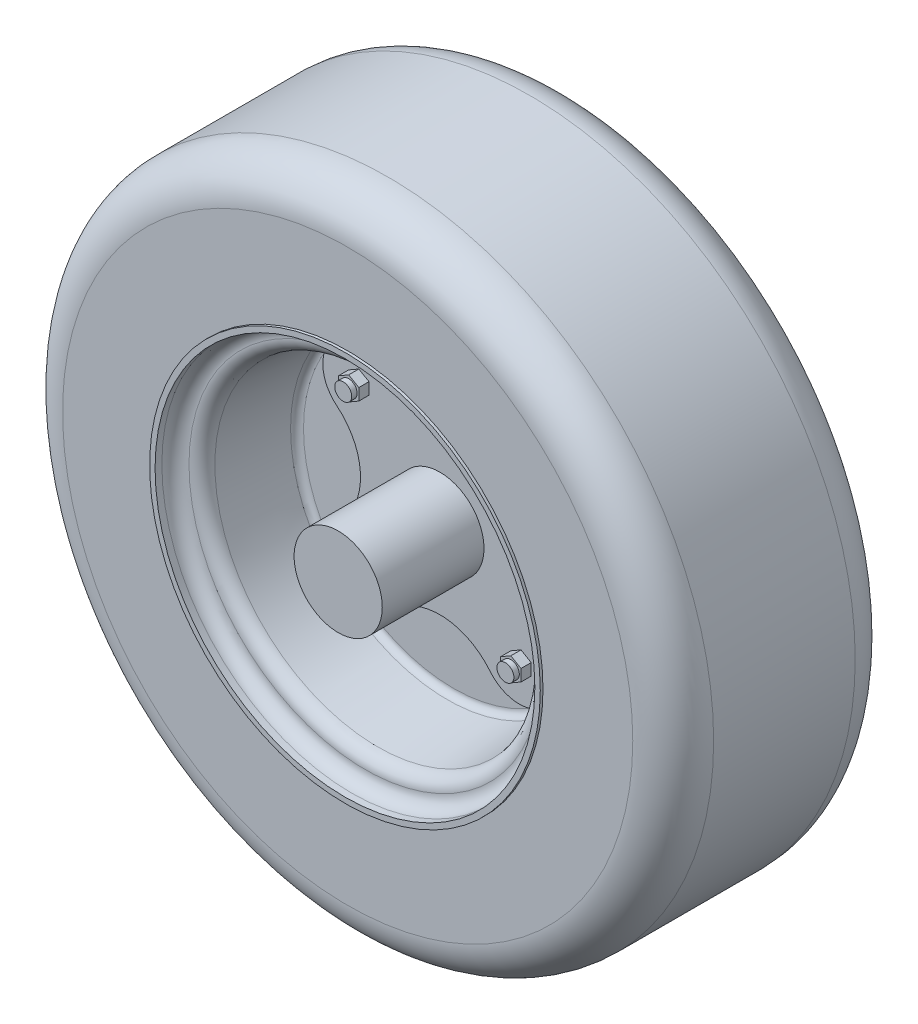
from build123d import *

# Parameters (mm, degrees)
BOSS_EXTRUDE5_DEPTH = 6.35
BOSS_EXTRUDE6_DEPTH = 4.7625
SKETCH15_R          = 3.96875
BOSS_EXTRUDE7_DEPTH = 2.54
SKETCH16_R          = 6.35
BOSS_EXTRUDE8_DEPTH = 4.7625


with BuildPart() as part:
    # Sketch6 → Revolve2 (revolve)
    with BuildSketch(Plane(origin=(-104.775, 0, 0), x_dir=(0, 0, -1), z_dir=(1, 0, 0))):
        with BuildLine():
            Line((-52.07, -141.9225), (-52.07, -99.897045455))
            ThreePointArc((-52.07, -99.897045455), (-46.524200035, -86.508299965), (-33.135454545, -80.9625))
            Line((-33.135454545, -80.9625), (-28.993522727, -80.9625))
            Line((-28.993522727, -80.9625), (-20.709659091, -80.9625))
            Line((-20.709659091, -80.9625), (-12.425795455, -80.9625))
            Line((-12.425795455, -80.9625), (-4.141931818, -80.9625))
            Line((-4.141931818, -80.9625), (4.141931818, -80.9625))
            Line((4.141931818, -80.9625), (12.425795455, -80.9625))
            Line((12.425795455, -80.9625), (20.709659091, -80.9625))
            Line((20.709659091, -80.9625), (28.993522727, -80.9625))
            Line((28.993522727, -80.9625), (33.135454545, -80.9625))
            ThreePointArc((33.135454545, -80.9625), (46.524200035, -86.508299965), (52.07, -99.897045455))
            Line((52.07, -99.897045455), (52.07, -141.9225))
            Line((52.07, -141.9225), (53.34, -141.9225))
            Line((53.34, -141.9225), (53.34, -144.4625))
            Line((53.34, -144.4625), (50.165, -144.4625))
            ThreePointArc((50.165, -144.4625), (45.674871939, -146.322371939), (43.815, -150.8125))
            ThreePointArc((43.815, -150.8125), (42.146711089, -155.102497818), (38.018438966, -157.138336333))
            Line((38.018438966, -157.138336333), (5.438280517, -159.988730853))
            ThreePointArc((5.438280517, -159.988730853), (3.374144456, -161.00665011), (2.54, -163.15164902))
            Line((2.54, -163.15164902), (2.54, -212.725))
            Line((2.54, -212.725), (53.34, -212.725))
            Line((53.34, -212.725), (56.515, -212.725))
            Line((56.515, -212.725), (56.515, -233.3625))
            Line((56.515, -233.3625), (-56.515, -233.3625))
            Line((-56.515, -233.3625), (-56.515, -212.725))
            Line((-56.515, -212.725), (-53.34, -212.725))
            Line((-53.34, -212.725), (-2.54, -212.725))
            Line((-2.54, -212.725), (-2.54, -163.15164902))
            ThreePointArc((-2.54, -163.15164902), (-3.374144456, -161.00665011), (-5.438280517, -159.988730853))
            Line((-5.438280517, -159.988730853), (-38.018438966, -157.138336333))
            ThreePointArc((-38.018438966, -157.138336333), (-42.146711089, -155.102497818), (-43.815, -150.8125))
            ThreePointArc((-43.815, -150.8125), (-45.674871939, -146.322371939), (-50.165, -144.4625))
            Line((-50.165, -144.4625), (-53.34, -144.4625))
            Line((-53.34, -144.4625), (-53.34, -141.9225))
            Line((-53.34, -141.9225), (-52.07, -141.9225))
        make_face()
    revolve(axis=Axis((-104.775, -233.3625, 111.145303652), (0, 0, -1)))

    # Sketch13 → Boss-Extrude5 (add)
    with BuildSketch(Plane.XY.offset(2.54)):
        with BuildLine():
            ThreePointArc((-153.078698148, -209.932127396), (-154.421568841, -183.715931159), (-128.205372604, -185.058801852))
            ThreePointArc((-128.205372604, -185.058801852), (-104.775, -196.200549673), (-81.344627396, -185.058801852))
            ThreePointArc((-81.344627396, -185.058801852), (-55.128431159, -183.715931159), (-56.471301852, -209.932127396))
            ThreePointArc((-56.471301852, -209.932127396), (-67.613049673, -233.3625), (-56.471301852, -256.792872604))
            ThreePointArc((-56.471301852, -256.792872604), (-55.128431159, -283.009068841), (-81.344627396, -281.666198148))
            ThreePointArc((-81.344627396, -281.666198148), (-104.775, -270.524450327), (-128.205372604, -281.666198148))
            ThreePointArc((-128.205372604, -281.666198148), (-154.421568841, -283.009068841), (-153.078698148, -256.792872604))
            ThreePointArc((-153.078698148, -256.792872604), (-141.936950327, -233.3625), (-153.078698148, -209.932127396))
        make_face()
    extrude(amount=BOSS_EXTRUDE5_DEPTH)

    # Sketch14 → Boss-Extrude6 (add)
    with BuildSketch(Plane.XY.offset(8.89)):
        Polygon((-142.73701796, -200.899743354), (-137.97451796, -198.150112697), (-137.97451796, -192.650851383), (-142.73701796, -189.901220726), (-147.49951796, -192.650851383), (-147.49951796, -198.150112697), align=None)
        Polygon((-62.05048204, -198.150112697), (-66.81298204, -200.899743354), (-71.57548204, -198.150112697), (-71.57548204, -192.650851383), (-66.81298204, -189.901220726), (-62.05048204, -192.650851383), align=None)
        Polygon((-66.81298204, -265.825256646), (-71.57548204, -268.574887303), (-71.57548204, -274.074148617), (-66.81298204, -276.823779274), (-62.05048204, -274.074148617), (-62.05048204, -268.574887303), align=None)
        Polygon((-147.49951796, -268.574887303), (-142.73701796, -265.825256646), (-137.97451796, -268.574887303), (-137.97451796, -274.074148617), (-142.73701796, -276.823779274), (-147.49951796, -274.074148617), align=None)
    extrude(amount=BOSS_EXTRUDE6_DEPTH)

    # Sketch15 → Boss-Extrude7 (add)
    with BuildSketch(Plane.XY.offset(13.6525)):
        with Locations((-142.73701796, -195.40048204)):
            Circle(SKETCH15_R)
        with Locations((-66.81298204, -195.40048204)):
            Circle(SKETCH15_R)
        with Locations((-142.73701796, -271.32451796)):
            Circle(SKETCH15_R)
        with Locations((-66.81298204, -271.32451796)):
            Circle(SKETCH15_R)
    extrude(amount=BOSS_EXTRUDE7_DEPTH)

    # Sketch16 → Boss-Extrude8 (add)
    with BuildSketch(Plane(origin=(0, 0, -2.54), x_dir=(-1, 0, 0), z_dir=(0, 0, -1))):
        with Locations((66.81298204, -195.40048204)):
            Circle(SKETCH16_R)
        with Locations((142.73701796, -195.40048204)):
            Circle(SKETCH16_R)
        with Locations((142.73701796, -271.32451796)):
            Circle(SKETCH16_R)
        with Locations((66.81298204, -271.32451796)):
            Circle(SKETCH16_R)
    extrude(amount=BOSS_EXTRUDE8_DEPTH)


solid = part.part
